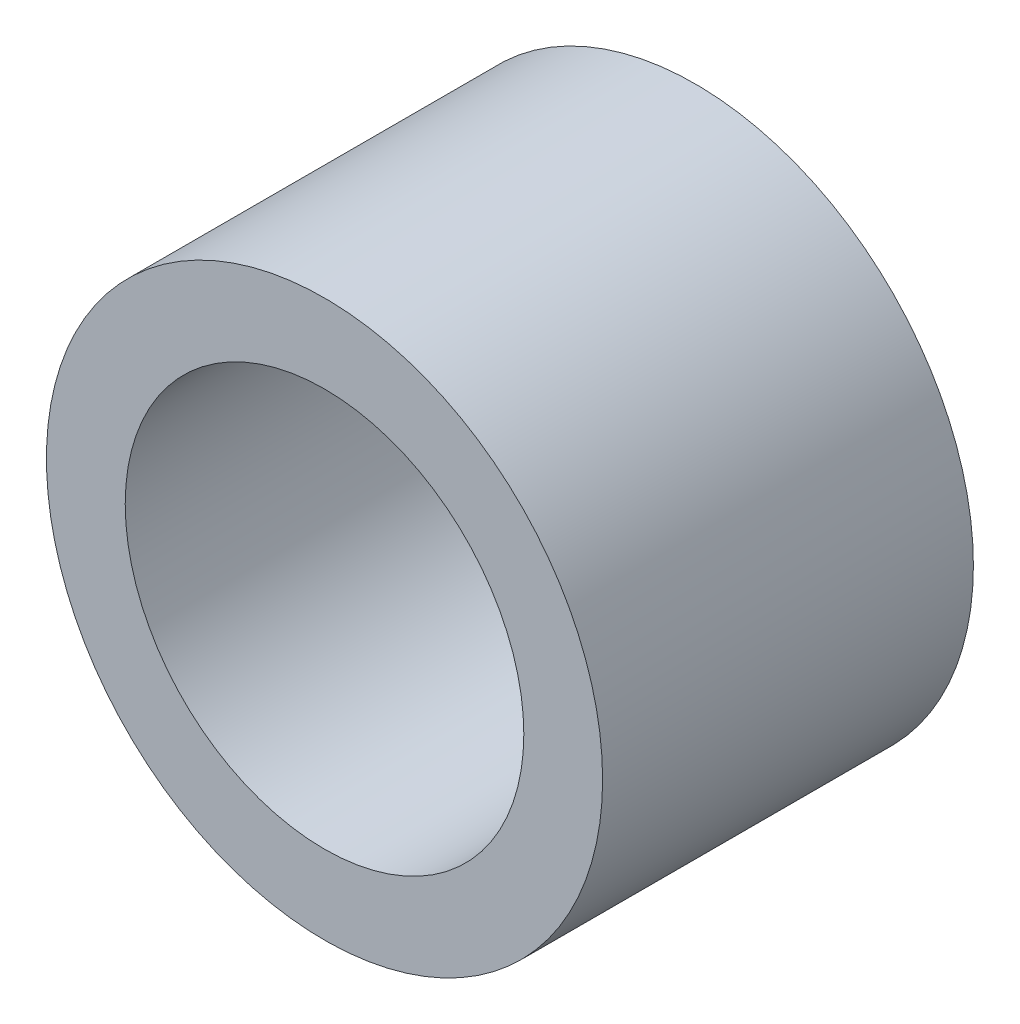
from build123d import *

# Parameters (mm, degrees)
SKETCH1_R           = 3
SKETCH1_R_2         = 2.15
BOSS_EXTRUDE1_DEPTH = 4


with BuildPart() as part:
    # Sketch1 → Boss-Extrude1 (new body)
    with BuildSketch(Plane.XY):
        Circle(SKETCH1_R)
        Circle(SKETCH1_R_2, mode=Mode.SUBTRACT)
    extrude(amount=BOSS_EXTRUDE1_DEPTH)


solid = part.part
